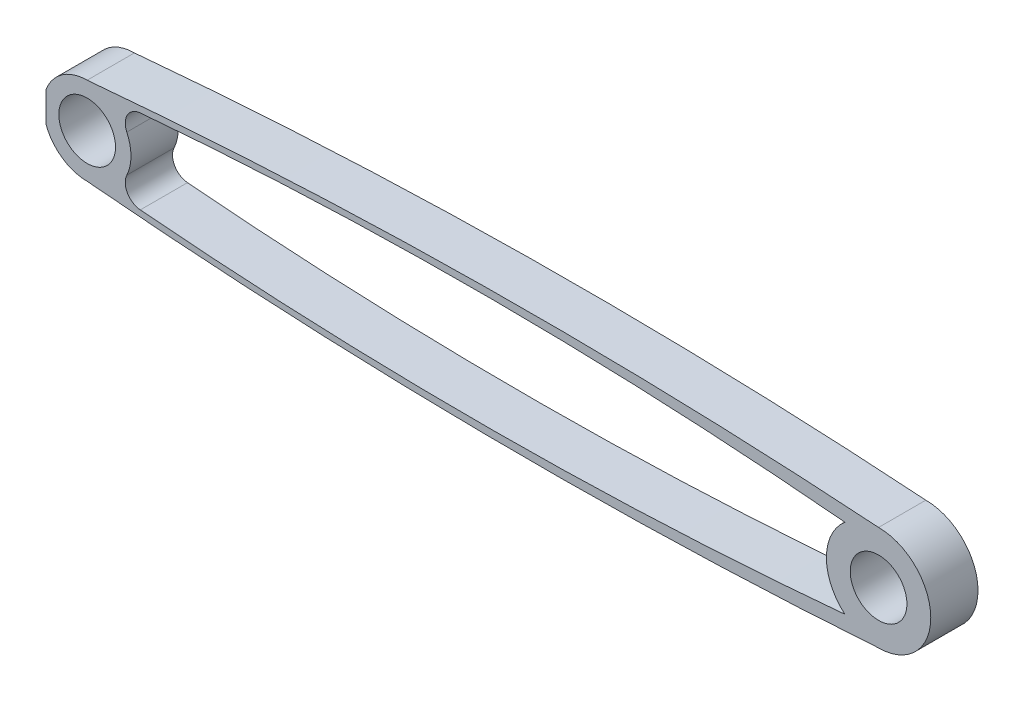
from build123d import *

# Parameters (mm, degrees)
SZKIC1_R                    = 3.000000079
DODANIE_WYCI_GNI_CIE1_DEPTH = 5
SZKIC2_W                    = 1.618528634
SZKIC2_H                    = 7.505645785
SZKIC2_W_2                  = 0.651830256
SZKIC2_H_2                  = 5.051684483
WYTNIJ_WYCI_GNI_CIE3_DEPTH  = 6


with BuildPart() as part:
    # Szkic1 → Dodanie-wyciągnięcie1 (new body)
    with BuildSketch(Plane.XY):
        with BuildLine():
            ThreePointArc((83.76241555, 5.522620658), (41.86347888, 6.752288216), (0, 4.635188213))
            ThreePointArc((0, 4.635188213), (-4.635188213, 0), (0, -4.635188213))
            ThreePointArc((0, -4.635188213), (41.86347888, -6.752288216), (83.76241555, -5.522620658))
            ThreePointArc((83.76241555, -5.522620658), (89.285036208, 0), (83.76241555, 5.522620658))
        make_face()
        with BuildLine():
            ThreePointArc((5.619311809, 4.445631254), (42.914384434, 5.983761034), (80.199446312, 4.219548453))
            ThreePointArc((80.199446312, 4.219548453), (78.239794892, 0), (80.199446312, -4.219548453))
            ThreePointArc((80.199446312, -4.219548453), (42.914384434, -5.983761034), (5.619311809, -4.445631254))
            ThreePointArc((5.619311809, -4.445631254), (4.261200111, -3.581390157), (4.194308577, -1.973004139))
            ThreePointArc((4.194308577, -1.973004139), (4.635188213, 0), (4.194308577, 1.973004139))
            ThreePointArc((4.194308577, 1.973004139), (4.261200111, 3.581390157), (5.619311809, 4.445631254))
        make_face(mode=Mode.SUBTRACT)
        with Locations((83.76241555, 0)):
            Circle(SZKIC1_R, mode=Mode.SUBTRACT)
        Circle(SZKIC1_R, mode=Mode.SUBTRACT)
    extrude(amount=DODANIE_WYCI_GNI_CIE1_DEPTH)

    # Szkic2 → Wytnij-wyciągnięcie3 (cut, through all)
    with BuildSketch(Plane.XY):
        with Locations((193.638606269, 0.381285041)):
            Rectangle(SZKIC2_W, SZKIC2_H)
        with Locations((-4.682734605, -0.038745932)):
            Rectangle(SZKIC2_W_2, SZKIC2_H_2)
    extrude(amount=WYTNIJ_WYCI_GNI_CIE3_DEPTH, mode=Mode.SUBTRACT)


solid = part.part
